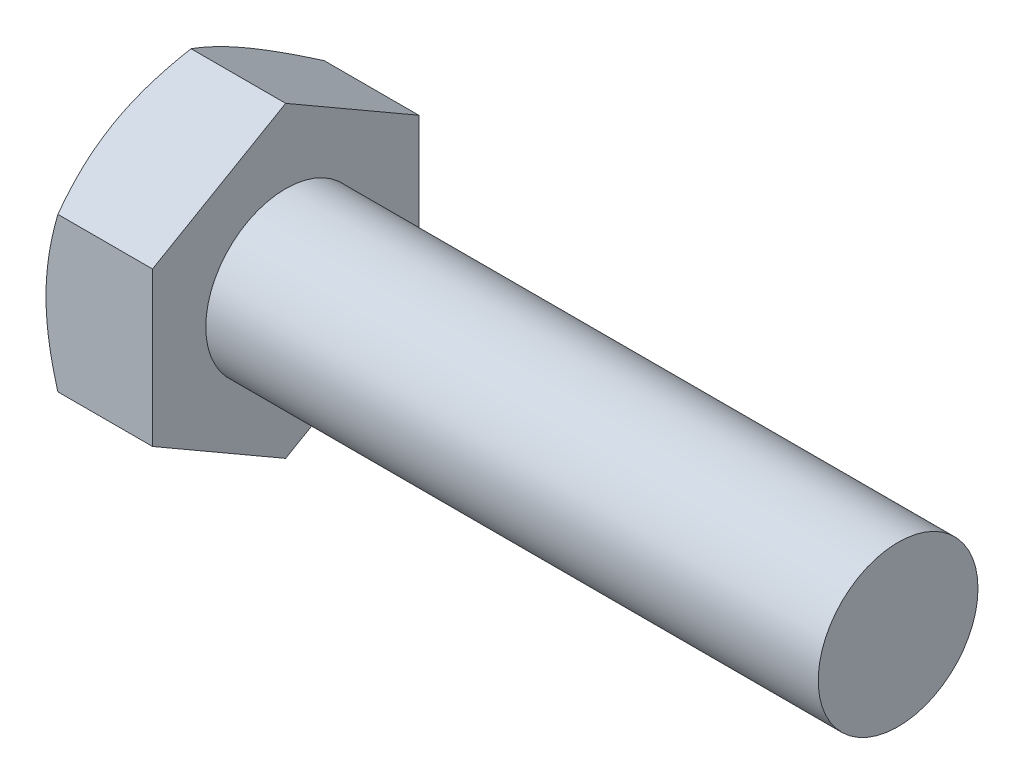
from build123d import *

# Parameters (mm, degrees)
SKETCH2_R           = 3
BOSS_EXTRUDE1_DEPTH = 30
CHAMFER1_SIZE       = 0.75
BOSS_EXTRUDE2_DEPTH = 4
SKETCH6_OUTSIDE_W   = 140.698
SKETCH6_OUTSIDE_H   = 142.246
SKETCH6_OUTSIDE_R   = 5
CUT_EXTRUDE1_DEPTH  = 35
CUT_EXTRUDE1_TAPER  = 60
SKETCH7_W           = 0.197562976
SKETCH7_H           = 0.197562976
CUT_EXTRUDE2_DEPTH  = 0.25
SKETCH10_R          = 3.903205457
CUT_EXTRUDE3_DEPTH  = 7


with BuildPart() as part:
    # Sketch2 → Boss-Extrude1 (new body)
    with BuildSketch(Plane(origin=(17, 0, 0), x_dir=(0, 0, -1), z_dir=(1, 0, 0))):
        Circle(SKETCH2_R)
    extrude(amount=-BOSS_EXTRUDE1_DEPTH)

    # Chamfer1
    chamfer1_edges = [part.edges().sort_by_distance(p)[0] for p in [
        (17, 0, 3),
    ]]
    chamfer(chamfer1_edges, length=CHAMFER1_SIZE)

    # Sketch3 → Boss-Extrude2 (add)
    with BuildSketch(Plane.ZY.offset(13)):
        Polygon((-5, -2.886751346), (0, -5.773502692), (5, -2.886751346), (5, 2.886751346), (0, 5.773502692), (-5, 2.886751346), align=None)
    extrude(amount=BOSS_EXTRUDE2_DEPTH)

    # Sketch6 outside → Cut-Extrude1 (cut, through all)
    with BuildSketch(Plane.ZY.offset(17)):
        Rectangle(SKETCH6_OUTSIDE_W, SKETCH6_OUTSIDE_H)
        Circle(SKETCH6_OUTSIDE_R, mode=Mode.SUBTRACT)
    extrude(amount=-CUT_EXTRUDE1_DEPTH, taper=CUT_EXTRUDE1_TAPER, mode=Mode.SUBTRACT)

    # Sketch7 → Cut-Extrude2 (cut)
    with BuildSketch(Plane.ZY.offset(17)):
        with BuildLine():
            Line((-1.284159342, 2.5), (-1.481722318, 2.5))
            Line((-1.481722318, 2.5), (-1.481722318, 3.700812462))
            add(Edge.make_bspline(
                [(-1.481722318, 3.700812462), (-1.493098012, 3.689842005), (-1.516741144, 3.667041113), (-1.556707362, 3.634772156), (-1.601314769, 3.602066201), (-1.649984109, 3.570615769), (-1.699594268, 3.541008578), (-1.7475361, 3.514381463), (-1.793009194, 3.491848462), (-1.822962567, 3.479527328), (-1.837335675, 3.47361504)],
                knots=[0, 0, 0, 0, 4.7391e-05, 9.8497e-05, 0.000153942, 0.000213277, 0.000272253, 0.000327241, 0.00037777, 0.000424383, 0.000424383, 0.000424383, 0.000424383], degree=3))
            Line((-1.837335675, 3.47361504), (-1.837335675, 3.655743408))
            add(Edge.make_bspline(
                [(-1.837335675, 3.655743408), (-1.812648378, 3.668457416), (-1.763991177, 3.693515971), (-1.695249075, 3.736795542), (-1.631070927, 3.783712378), (-1.572519137, 3.834256092), (-1.520031188, 3.885920841), (-1.475798832, 3.938052602), (-1.438788011, 3.98874045), (-1.42021898, 4.024089603), (-1.411340508, 4.040991211)],
                knots=[0, 0, 0, 0, 8.3274e-05, 0.000164129, 0.000243405, 0.000321553, 0.000395986, 0.000464089, 0.000526529, 0.000583737, 0.000583737, 0.000583737, 0.000583737], degree=3))
            Line((-1.411340508, 4.040991211), (-1.284159342, 4.040991211))
            Line((-1.284159342, 4.040991211), (-1.284159342, 2.5))
        make_face()
        with BuildLine():
            add(Edge.make_bspline(
                [(-0.790251903, 3.260000072), (-0.790052858, 3.282022251), (-0.789663013, 3.325154426), (-0.787244933, 3.388264546), (-0.783023159, 3.448197614), (-0.776721214, 3.50490158), (-0.769258531, 3.558504437), (-0.759556995, 3.608929689), (-0.748641356, 3.656290471), (-0.735544549, 3.700537418), (-0.721155446, 3.742050974), (-0.704830549, 3.780764541), (-0.686462825, 3.816637074), (-0.666954934, 3.85004059), (-0.645279941, 3.880455529), (-0.622746104, 3.908735457), (-0.597715799, 3.933843239), (-0.57122984, 3.956424902), (-0.542898213, 3.976351902), (-0.512870822, 3.993546501), (-0.481263204, 4.008728091), (-0.447472952, 4.020156788), (-0.412201546, 4.029473599), (-0.375177484, 4.036327159), (-0.336359967, 4.040367563), (-0.309833651, 4.04078098), (-0.296344464, 4.040991211)],
                knots=[0, 0, 0, 0, 6.6067e-05, 0.000129397, 0.000189439, 0.000246266, 0.00030053, 0.000351748, 0.000400268, 0.000446276, 0.000490111, 0.000532023, 0.000572197, 0.00061095, 0.000647948, 0.000684154, 0.000719298, 0.00075412, 0.000788462, 0.000823037, 0.000857836, 0.000893469, 0.000929859, 0.000967215, 0.001006317, 0.001046775, 0.001046775, 0.001046775, 0.001046775], degree=3))
            add(Edge.make_bspline(
                [(-0.296344464, 4.040991211), (-0.276554072, 4.040409387), (-0.237675053, 4.039266372), (-0.180911485, 4.029944144), (-0.127415481, 4.013997036), (-0.077221797, 3.992483699), (-0.031188485, 3.965157621), (0.009921203, 3.93193861), (0.045663832, 3.893175459), (0.075649327, 3.848408838), (0.101859643, 3.798873708), (0.125144312, 3.744347738), (0.146192977, 3.68489203), (0.161129567, 3.631670872), (0.171783825, 3.585728479), (0.178836097, 3.547836494), (0.184690897, 3.506950828), (0.189176465, 3.463170395), (0.192856768, 3.416544299), (0.195698897, 3.36704351), (0.197141568, 3.314544309), (0.197419873, 3.278522328), (0.197562976, 3.260000072)],
                knots=[0, 0, 0, 0, 5.9349e-05, 0.000116594, 0.000171974, 0.000226451, 0.000280026, 0.000332045, 0.000384478, 0.000437563, 0.000493218, 0.000552397, 0.000615273, 0.000682311, 0.000718105, 0.000756732, 0.0007979, 0.000841978, 0.000888737, 0.000938206, 0.000990706, 0.001046274, 0.001046274, 0.001046274, 0.001046274], degree=3))
            add(Edge.make_bspline(
                [(0.197562976, 3.260000072), (0.197360203, 3.238081335), (0.196964045, 3.195258767), (0.194610758, 3.132654684), (0.190134593, 3.073173782), (0.184626591, 3.016679807), (0.176294137, 2.963323573), (0.167315467, 2.912878383), (0.156211069, 2.865573301), (0.143254845, 2.821387596), (0.128663193, 2.78008763), (0.11266119, 2.74136128), (0.094937435, 2.705235008), (0.074964401, 2.672061172), (0.053655947, 2.641399446), (0.03085601, 2.613134809), (0.006081205, 2.587674071), (-0.020643434, 2.565160142), (-0.048776137, 2.544879764), (-0.07887653, 2.527515404), (-0.110812868, 2.513129332), (-0.144371773, 2.500829956), (-0.179893749, 2.491817695), (-0.217098671, 2.484918949), (-0.256123623, 2.480856468), (-0.282752541, 2.480450776), (-0.296344464, 2.480243702)],
                knots=[0, 0, 0, 0, 6.5758e-05, 0.000128471, 0.000187897, 0.000244692, 0.000298695, 0.000349857, 0.000398377, 0.000444384, 0.000487929, 0.000529721, 0.000570032, 0.00060852, 0.00064577, 0.000681977, 0.000717341, 0.000752163, 0.000786684, 0.000821259, 0.000856208, 0.000891654, 0.000928341, 0.000966002, 0.001005104, 0.00104587, 0.00104587, 0.00104587, 0.00104587], degree=3))
            add(Edge.make_bspline(
                [(-0.296344464, 2.480243702), (-0.31416505, 2.480752036), (-0.348910289, 2.481743145), (-0.399653148, 2.488477126), (-0.447278028, 2.500329248), (-0.492186617, 2.516224614), (-0.533874131, 2.537485582), (-0.572539611, 2.563353701), (-0.608960011, 2.593227122), (-0.629925808, 2.616796566), (-0.64053621, 2.628724626)],
                knots=[0, 0, 0, 0, 5.3461e-05, 0.000104234, 0.000153198, 0.000200459, 0.000246846, 0.000293164, 0.000339842, 0.000387669, 0.000387669, 0.000387669, 0.000387669], degree=3))
            add(Edge.make_bspline(
                [(-0.64053621, 2.628724626), (-0.652749028, 2.646341795), (-0.677932381, 2.682669151), (-0.707407312, 2.744610663), (-0.733699472, 2.81279957), (-0.754333998, 2.888573732), (-0.770495975, 2.971330072), (-0.782168957, 3.061230974), (-0.788774716, 3.158237599), (-0.789748392, 3.225313505), (-0.790251903, 3.260000072)],
                knots=[0, 0, 0, 0, 6.4214e-05, 0.000132412, 0.000205106, 0.000283297, 0.000367629, 0.000457915, 0.000555082, 0.00065914, 0.00065914, 0.00065914, 0.00065914], degree=3))
        make_face()
        with BuildLine():
            add(Edge.make_bspline(
                [(-0.592688927, 3.260617457), (-0.592492763, 3.230978591), (-0.592117261, 3.174243246), (-0.588194178, 3.093187016), (-0.581440751, 3.020063233), (-0.57251228, 2.954973141), (-0.560723083, 2.897828693), (-0.545920352, 2.84877551), (-0.529234153, 2.807224843), (-0.508585298, 2.77369168), (-0.485977083, 2.746357261), (-0.462635646, 2.722848776), (-0.438011843, 2.702867102), (-0.412266343, 2.686206461), (-0.384999685, 2.673592119), (-0.356510025, 2.664449215), (-0.326791165, 2.659187614), (-0.30655127, 2.658431621), (-0.296344464, 2.658050381)],
                knots=[0, 0, 0, 0, 8.8912e-05, 0.000170197, 0.000243364, 0.000309153, 0.000367215, 0.000418189, 0.000462736, 0.000501119, 0.000535784, 0.000568962, 0.000600347, 0.000630747, 0.000660715, 0.000690198, 0.000720294, 0.00075091, 0.00075091, 0.00075091, 0.00075091], degree=3))
            add(Edge.make_bspline(
                [(-0.296344464, 2.658050381), (-0.286140213, 2.658439952), (-0.265905387, 2.659212463), (-0.236117858, 2.66435804), (-0.207739045, 2.673971614), (-0.180513042, 2.686541403), (-0.154580415, 2.702822298), (-0.130077548, 2.722879447), (-0.106613153, 2.746373973), (-0.084106493, 2.774026105), (-0.063614954, 2.807714303), (-0.046615742, 2.849231123), (-0.032043703, 2.898370213), (-0.020189817, 2.955485547), (-0.011224514, 3.020472726), (-0.00451192, 3.093393697), (-0.000562582, 3.174345633), (-0.000193277, 3.230978457), (0, 3.260617457)],
                knots=[0, 0, 0, 0, 3.0617e-05, 6.0712e-05, 9.029e-05, 0.000120259, 0.000150493, 0.000181878, 0.000215057, 0.000249961, 0.000288608, 0.00033287, 0.00038414, 0.000442201, 0.000507685, 0.000580852, 0.000661829, 0.000750741, 0.000750741, 0.000750741, 0.000750741], degree=3))
            add(Edge.make_bspline(
                [(0, 3.260617457), (-0.000187089, 3.289639765), (-0.000545544, 3.345245408), (-0.00459674, 3.424740087), (-0.010945329, 3.496636517), (-0.01962919, 3.56100098), (-0.03117004, 3.6177636), (-0.045167517, 3.667045216), (-0.061847603, 3.708740728), (-0.081680166, 3.743268967), (-0.103757778, 3.77159149), (-0.126819935, 3.796107098), (-0.151443196, 3.816956825), (-0.178063809, 3.833682782), (-0.205823744, 3.847176663), (-0.235360851, 3.856463495), (-0.266384805, 3.862169035), (-0.287676143, 3.862842166), (-0.298505309, 3.863184533)],
                knots=[0, 0, 0, 0, 8.706e-05, 0.000166804, 0.000238713, 0.000303542, 0.00036154, 0.000412338, 0.000457052, 0.000495915, 0.000531356, 0.000564545, 0.000596758, 0.000627844, 0.000658634, 0.000689093, 0.000720458, 0.000752924, 0.000752924, 0.000752924, 0.000752924], degree=3))
            add(Edge.make_bspline(
                [(-0.298505309, 3.863184533), (-0.308711474, 3.862916661), (-0.328836725, 3.862388453), (-0.358302727, 3.857346709), (-0.386227312, 3.84891579), (-0.412930404, 3.837495291), (-0.437745374, 3.822125556), (-0.461656324, 3.804180295), (-0.483543356, 3.782315999), (-0.49673229, 3.765970592), (-0.503476896, 3.757611818)],
                knots=[0, 0, 0, 0, 3.0599e-05, 6.0338e-05, 8.9344e-05, 0.000117961, 0.000147184, 0.000176696, 0.000207474, 0.000239686, 0.000239686, 0.000239686, 0.000239686], degree=3))
            add(Edge.make_bspline(
                [(-0.503476896, 3.757611818), (-0.510819714, 3.745335366), (-0.5263262, 3.719410087), (-0.543677057, 3.674350882), (-0.559004117, 3.622856788), (-0.57162337, 3.56413553), (-0.580752514, 3.49828784), (-0.58795962, 3.425390186), (-0.591703443, 3.345340795), (-0.592351369, 3.289637751), (-0.592688927, 3.260617457)],
                knots=[0, 0, 0, 0, 4.2846e-05, 9.0482e-05, 0.000144294, 0.000203994, 0.000270438, 0.000343635, 0.000423687, 0.000510752, 0.000510752, 0.000510752, 0.000510752], degree=3))
        make_face(mode=Mode.SUBTRACT)
        with Locations((0.592688927, 2.598781488)):
            Rectangle(SKETCH7_W, SKETCH7_H)
        with BuildLine():
            Line((1.007571176, 2.875369654), (1.205134152, 2.895125952))
            add(Edge.make_bspline(
                [(1.205134152, 2.895125952), (1.206920239, 2.885003602), (1.210372897, 2.865436243), (1.218164458, 2.837549402), (1.226067012, 2.811547623), (1.236268145, 2.788010165), (1.246891881, 2.766297683), (1.258922971, 2.746627755), (1.272575767, 2.729395444), (1.291855309, 2.709202247), (1.319210172, 2.688130304), (1.357127719, 2.671061208), (1.398840582, 2.65958445), (1.428236664, 2.658573426), (1.443444492, 2.658050381)],
                knots=[0, 0, 0, 0, 3.0815e-05, 5.9568e-05, 8.6805e-05, 0.00011226, 0.000136419, 0.000159292, 0.000181276, 0.000202236, 0.000242984, 0.000283862, 0.000326316, 0.000371821, 0.000371821, 0.000371821, 0.000371821], degree=3))
            add(Edge.make_bspline(
                [(1.443444492, 2.658050381), (1.456751488, 2.658529578), (1.482941721, 2.659472712), (1.521127946, 2.666783962), (1.557442454, 2.678496432), (1.591253108, 2.695301374), (1.622436856, 2.71575252), (1.649674808, 2.7400526), (1.673330676, 2.767155041), (1.692759492, 2.798382253), (1.709342511, 2.83404897), (1.725011258, 2.8746088), (1.739833634, 2.920760517), (1.753006889, 2.971915473), (1.764802895, 3.026206092), (1.773081217, 3.082402208), (1.778174547, 3.13941128), (1.778719417, 3.177774463), (1.778992858, 3.197026874)],
                knots=[0, 0, 0, 0, 3.9898e-05, 7.8525e-05, 0.000116206, 0.000154033, 0.000191447, 0.000227747, 0.000263205, 0.000299002, 0.000337663, 0.000381058, 0.000429381, 0.00048299, 0.000539478, 0.000595969, 0.000653291, 0.000711037, 0.000711037, 0.000711037, 0.000711037], degree=3))
            add(Edge.make_bspline(
                [(1.778992858, 3.197026874), (1.778899344, 3.202274865), (1.778675616, 3.214830375), (1.778290769, 3.227382036), (1.778066782, 3.234687316)],
                knots=[0, 0, 0, 0, 1.5746e-05, 3.7672e-05, 3.7672e-05, 3.7672e-05, 3.7672e-05], degree=3))
            add(Edge.make_bspline(
                [(1.778066782, 3.234687316), (1.768542584, 3.22022413), (1.749509536, 3.191321063), (1.714445959, 3.152529649), (1.674332612, 3.118121138), (1.629778386, 3.088362715), (1.58188343, 3.063940569), (1.531480967, 3.046194448), (1.479005485, 3.035236452), (1.443291513, 3.034030076), (1.425231655, 3.033420035)],
                knots=[0, 0, 0, 0, 5.1893e-05, 0.000103703, 0.000156237, 0.000210089, 0.000264068, 0.000317082, 0.000369993, 0.000424121, 0.000424121, 0.000424121, 0.000424121], degree=3))
            add(Edge.make_bspline(
                [(1.425231655, 3.033420035), (1.410181713, 3.033809962), (1.380555612, 3.034577542), (1.337158587, 3.041399547), (1.295419155, 3.051630137), (1.255732843, 3.067119745), (1.21748219, 3.086276405), (1.181068826, 3.109789736), (1.146436643, 3.137627733), (1.114033143, 3.169443767), (1.084462099, 3.2049069), (1.05838385, 3.243153184), (1.036728508, 3.28436963), (1.018710514, 3.328041798), (1.004807734, 3.374591649), (0.995147123, 3.423910112), (0.988649898, 3.475808926), (0.98809691, 3.511357846), (0.987814879, 3.529488319)],
                knots=[0, 0, 0, 0, 4.5121e-05, 8.8821e-05, 0.000131497, 0.000173806, 0.000216326, 0.000259653, 0.000303572, 0.000349412, 0.000395655, 0.000441889, 0.000488011, 0.000535076, 0.000583418, 0.000633484, 0.000685711, 0.000740072, 0.000740072, 0.000740072, 0.000740072], degree=3))
            add(Edge.make_bspline(
                [(0.987814879, 3.529488319), (0.988237289, 3.548232953), (0.989063596, 3.584900708), (0.995305351, 3.63851352), (1.005631769, 3.689304987), (1.020691426, 3.737178163), (1.039315186, 3.782440645), (1.062799025, 3.824766099), (1.090238676, 3.864335583), (1.12179809, 3.900767612), (1.1564816, 3.933457226), (1.193305446, 3.962633275), (1.232749472, 3.986615849), (1.274057373, 4.006611333), (1.317541757, 4.022064144), (1.363128302, 4.033233279), (1.410943155, 4.039786979), (1.443527149, 4.040584988), (1.460113868, 4.040991211)],
                knots=[0, 0, 0, 0, 5.6224e-05, 0.000109983, 0.000161685, 0.000211479, 0.000260324, 0.000308267, 0.000356392, 0.00040454, 0.000452579, 0.000499201, 0.000545208, 0.00059077, 0.000636661, 0.00068338, 0.000731358, 0.000781105, 0.000781105, 0.000781105, 0.000781105], degree=3))
            add(Edge.make_bspline(
                [(1.460113868, 4.040991211), (1.472160605, 4.04074757), (1.49610549, 4.040263292), (1.53174045, 4.036565994), (1.56653158, 4.029901008), (1.600705712, 4.021487923), (1.633686425, 4.009809927), (1.666109474, 3.996305519), (1.697583789, 3.979788608), (1.728292766, 3.961006809), (1.758043531, 3.940290273), (1.78541595, 3.916489215), (1.811504082, 3.891230711), (1.835777069, 3.863722031), (1.857467159, 3.833538628), (1.878046883, 3.801747632), (1.896524197, 3.767655353), (1.913374225, 3.731215619), (1.928371403, 3.691678329), (1.940882807, 3.648169752), (1.951607872, 3.600539191), (1.960537546, 3.548723511), (1.967159045, 3.492759655), (1.972032081, 3.432730793), (1.975222249, 3.368591267), (1.975491252, 3.324417814), (1.975629758, 3.301673513)],
                knots=[0, 0, 0, 0, 3.6138e-05, 7.183e-05, 0.00010731, 0.000142349, 0.000177298, 0.000212157, 0.00024764, 0.0002838, 0.000320115, 0.000356243, 0.00039248, 0.000429011, 0.000466118, 0.000503881, 0.00054256, 0.000582338, 0.000624249, 0.000669281, 0.000718032, 0.000770659, 0.000826944, 0.000887033, 0.000951315, 0.001019543, 0.001019543, 0.001019543, 0.001019543], degree=3))
            add(Edge.make_bspline(
                [(1.975629758, 3.301673513), (1.975490325, 3.277900399), (1.975218576, 3.231567557), (1.972003363, 3.163933366), (1.967132776, 3.099998865), (1.960506598, 3.039722069), (1.951514674, 2.983194972), (1.940827057, 2.930427456), (1.928222834, 2.881322105), (1.913411036, 2.835874606), (1.896572884, 2.793562676), (1.878123243, 2.753865304), (1.857460667, 2.716841197), (1.834817321, 2.682419349), (1.81048396, 2.650539597), (1.784080657, 2.621287341), (1.755598839, 2.594751007), (1.725401557, 2.570631953), (1.69353413, 2.54937701), (1.660430384, 2.530622167), (1.625716723, 2.515258667), (1.589750014, 2.502655004), (1.552594169, 2.492248635), (1.513946549, 2.485236805), (1.473985704, 2.481265544), (1.446951668, 2.480587277), (1.433257651, 2.480243702)],
                knots=[0, 0, 0, 0, 7.1314e-05, 0.000138988, 0.000203078, 0.000263655, 0.00032085, 0.000374731, 0.00042512, 0.000472855, 0.000518026, 0.000561664, 0.00060409, 0.0006451, 0.000685171, 0.000724292, 0.000763168, 0.000801832, 0.000840102, 0.000877971, 0.000915833, 0.000953813, 0.000992231, 0.001031465, 0.001071488, 0.001112573, 0.001112573, 0.001112573, 0.001112573], degree=3))
            add(Edge.make_bspline(
                [(1.433257651, 2.480243702), (1.418732748, 2.480494839), (1.390314716, 2.480986189), (1.348827314, 2.486152771), (1.309305056, 2.494007659), (1.271862965, 2.505603334), (1.236220636, 2.519877298), (1.202986414, 2.538118612), (1.171569683, 2.559163632), (1.142358031, 2.583436747), (1.115693486, 2.610848821), (1.091567168, 2.640724272), (1.070415495, 2.673450039), (1.052349162, 2.70883318), (1.036346581, 2.746576015), (1.023940229, 2.787184652), (1.013861262, 2.83028456), (1.00970173, 2.860098607), (1.007571176, 2.875369654)],
                knots=[0, 0, 0, 0, 4.3553e-05, 8.5212e-05, 0.000125229, 0.000164288, 0.000202638, 0.000240208, 0.000277794, 0.000315934, 0.000353917, 0.000392341, 0.000430957, 0.000470581, 0.0005114, 0.000553773, 0.000597803, 0.000644038, 0.000644038, 0.000644038, 0.000644038], degree=3))
        make_face()
        with BuildLine():
            add(Edge.make_bspline(
                [(1.778066782, 3.533810009), (1.777844584, 3.546167498), (1.777412091, 3.570220558), (1.773622923, 3.605313673), (1.767526176, 3.638360963), (1.758968941, 3.669552455), (1.747347963, 3.698557507), (1.733885852, 3.72605331), (1.717423045, 3.751277762), (1.698847657, 3.774570528), (1.678386493, 3.79540537), (1.656104474, 3.813571489), (1.632419371, 3.829143971), (1.606762975, 3.84138813), (1.579978695, 3.851477273), (1.551423134, 3.858071145), (1.521489215, 3.862690284), (1.500880058, 3.863017562), (1.490365698, 3.863184533)],
                knots=[0, 0, 0, 0, 3.7064e-05, 7.2142e-05, 0.000105744, 0.000137801, 0.000168985, 0.000199356, 0.000229496, 0.000259145, 0.000288613, 0.000316913, 0.000345254, 0.000373418, 0.000402033, 0.000430934, 0.000461187, 0.000492698, 0.000492698, 0.000492698, 0.000492698], degree=3))
            add(Edge.make_bspline(
                [(1.490365698, 3.863184533), (1.479550713, 3.862856809), (1.458245164, 3.862211193), (1.427017644, 3.858053397), (1.397402188, 3.850092498), (1.36919886, 3.839532546), (1.342094419, 3.826470071), (1.317074221, 3.809354236), (1.29309033, 3.789957753), (1.271104705, 3.76745525), (1.251021561, 3.742783687), (1.233326098, 3.716174633), (1.218424276, 3.687615052), (1.206512128, 3.657224018), (1.19677715, 3.625266419), (1.190089912, 3.591456506), (1.18597516, 3.555830273), (1.185579924, 3.531454958), (1.185377855, 3.518992786)],
                knots=[0, 0, 0, 0, 3.2449e-05, 6.3925e-05, 9.425e-05, 0.000124237, 0.000154195, 0.000184246, 0.000214957, 0.000246608, 0.000278428, 0.000310277, 0.000342309, 0.000374869, 0.000408073, 0.000442399, 0.000478125, 0.000515497, 0.000515497, 0.000515497, 0.000515497], degree=3))
            add(Edge.make_bspline(
                [(1.185377855, 3.518992786), (1.185564481, 3.50786364), (1.185930382, 3.48604371), (1.190287864, 3.454199511), (1.196100099, 3.423807131), (1.2053659, 3.395176801), (1.216528497, 3.367892863), (1.231036441, 3.342581934), (1.247371005, 3.318487167), (1.266510109, 3.29641574), (1.287668429, 3.276393087), (1.31077761, 3.258941189), (1.335545758, 3.244002062), (1.36220298, 3.231978182), (1.390589415, 3.222718025), (1.420641701, 3.215900682), (1.452490468, 3.211840104), (1.474301842, 3.211433897), (1.485426624, 3.211226713)],
                knots=[0, 0, 0, 0, 3.3362e-05, 6.5409e-05, 9.6285e-05, 0.000126062, 0.00015553, 0.000184554, 0.000213409, 0.00024274, 0.000272002, 0.000300649, 0.000329449, 0.000358599, 0.000388177, 0.00041888, 0.000450928, 0.000484289, 0.000484289, 0.000484289, 0.000484289], degree=3))
            add(Edge.make_bspline(
                [(1.485426624, 3.211226713), (1.495831895, 3.211435921), (1.516311795, 3.211847691), (1.546312698, 3.215925579), (1.574819195, 3.222755565), (1.601959278, 3.232041219), (1.627688956, 3.244060942), (1.651835213, 3.259118787), (1.674864814, 3.276371256), (1.696102673, 3.296529924), (1.715513299, 3.318849511), (1.732299881, 3.343550515), (1.746634721, 3.37018436), (1.7579177, 3.399066744), (1.76695483, 3.429842075), (1.773317571, 3.462705196), (1.777484418, 3.497585953), (1.777869725, 3.521552704), (1.778066782, 3.533810009)],
                knots=[0, 0, 0, 0, 3.1202e-05, 6.1413e-05, 9.0614e-05, 0.000119022, 0.000147331, 0.000175602, 0.000204249, 0.000233512, 0.000263278, 0.000292817, 0.000322924, 0.000353821, 0.000385665, 0.000419023, 0.000454135, 0.00049089, 0.00049089, 0.00049089, 0.00049089], degree=3))
        make_face(mode=Mode.SUBTRACT)
    extrude(amount=-CUT_EXTRUDE2_DEPTH, mode=Mode.SUBTRACT)

    # Sketch9 → Revolve1 (revolve)
    with BuildSketch(Plane.XY):
        Polygon((-13, 3), (-13, 0), (2, 0), (-1, 3), align=None)
    revolve(axis=Axis((-13, 0, 0), (1, 0, 0)))

    # Sketch10 → Cut-Extrude3 (cut)
    with BuildSketch(Plane(origin=(17, 0, 0), x_dir=(0, 0, -1), z_dir=(1, 0, 0))):
        Circle(SKETCH10_R)
    extrude(amount=-CUT_EXTRUDE3_DEPTH, mode=Mode.SUBTRACT)


solid = part.part
